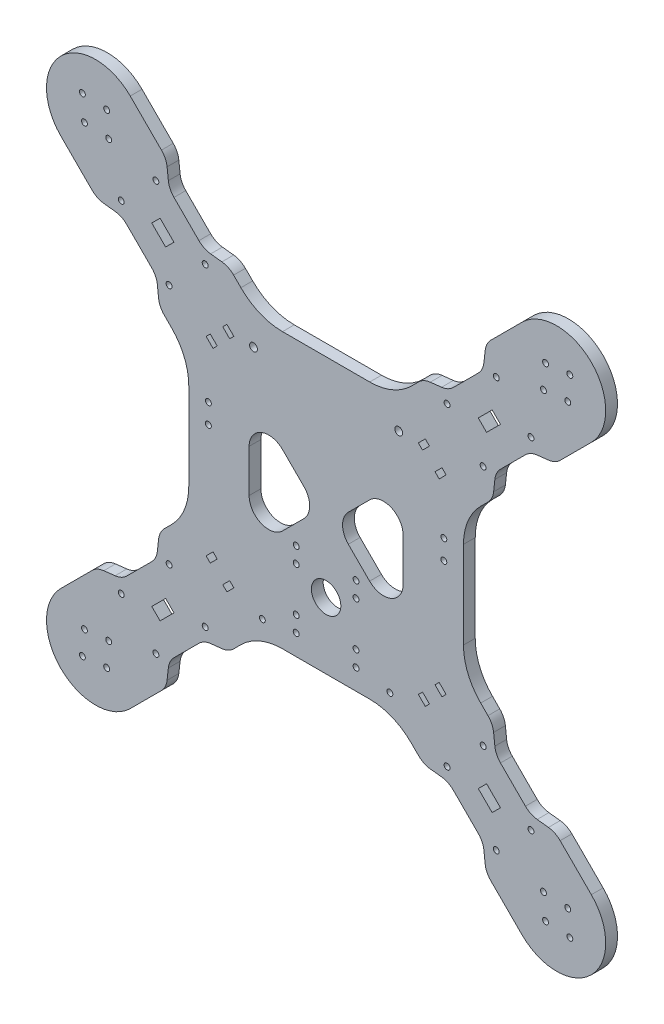
from build123d import *

# Parameters (mm, degrees)
BOSS_EXTRUDE1_DEPTH      = 6
FILLET1_R                = 30
SKETCH8_R                = 1.5
CUT_EXTRUDE1_DEPTH       = 202.614731605
SKETCH9_R                = 1.5
CUT_EXTRUDE2_DEPTH       = 202.614731605
MIRROR2_COPY_1_SKETCH_R  = 1.5
MIRROR2_COPY_1_DEPTH     = 202.614731605
MIRROR2_COPY_2_SKETCH_R  = 1.5
MIRROR2_COPY_2_DEPTH     = 202.614731605
MIRROR2_COPY_3_SKETCH_R  = 1.5
MIRROR2_COPY_3_DEPTH     = 202.614731605
MIRROR2_COPY_4_SKETCH_R  = 1.5
MIRROR2_COPY_4_DEPTH     = 202.614731605
CUT_EXTRUDE3_DEPTH       = 202.614731605
CUT_EXTRUDE3_DEPTH_BACK  = 202.614731605
SKETCH10_R               = 1.5
SKETCH10_R_2             = 1.499999999
SKETCH10_R_3             = 7.5
SKETCH10_R_4             = 2
FILLET2_R                = 10
CUT_EXTRUDE4_DEPTH       = 202.614731605
CIRPATTERN2_COUNT        = 4
CIRPATTERN2_COPY_1_DEPTH = 202.614731605
CIRPATTERN2_COPY_2_DEPTH = 202.614731605
CIRPATTERN2_COPY_3_DEPTH = 202.614731605
FILLET3_R                = 10


with BuildPart() as part:
    # Sketch4 → Boss-Extrude1 (new body)
    with BuildSketch(Plane.XY):
        with BuildLine():
            Line((-70, -34.644660941), (-70, 34.644660941))
            Line((-70, 34.644660941), (-135.17766953, 99.82233047))
            ThreePointArc((-135.17766953, 99.82233047), (-135.17766953, 135.17766953), (-99.82233047, 135.17766953))
            Line((-99.82233047, 135.17766953), (-34.644660941, 70))
            Line((-34.644660941, 70), (34.644660941, 70))
            Line((34.644660941, 70), (99.82233047, 135.17766953))
            ThreePointArc((99.82233047, 135.17766953), (135.17766953, 135.17766953), (135.17766953, 99.82233047))
            Line((135.17766953, 99.82233047), (70, 34.644660941))
            Line((70, 34.644660941), (70, -34.644660941))
            Line((70, -34.644660941), (135.17766953, -99.82233047))
            ThreePointArc((135.17766953, -99.82233047), (135.17766953, -135.17766953), (99.82233047, -135.17766953))
            Line((99.82233047, -135.17766953), (34.644660941, -70))
            Line((34.644660941, -70), (-34.644660941, -70))
            Line((-34.644660941, -70), (-99.82233047, -135.17766953))
            ThreePointArc((-99.82233047, -135.17766953), (-135.17766953, -135.17766953), (-135.17766953, -99.82233047))
            Line((-135.17766953, -99.82233047), (-70, -34.644660941))
        make_face()
    extrude(amount=BOSS_EXTRUDE1_DEPTH)

    # Fillet1
    fillet1_edges = [part.edges().sort_by_distance(p)[0] for p in [
        (34.644660941, -70, 3),
        (70, -34.644660941, 3),
        (70, 34.644660941, 3),
        (34.644660941, 70, 3),
        (-34.644660941, 70, 3),
        (-70, 34.644660941, 3),
        (-70, -34.644660941, 3),
        (-34.644660941, -70, 3),
    ]]
    fillet(fillet1_edges, radius=FILLET1_R)

    # Sketch8 → Cut-Extrude1 (cut, symmetric)
    with BuildSketch(Plane.XY.offset(6)):
        with Locations((-104.418524548, 86.740855018)):
            Circle(SKETCH8_R)
        with Locations((-80.023340597, 61.638564286)):
            Circle(SKETCH8_R)
        with Locations((-86.740855018, 104.418524548)):
            Circle(SKETCH8_R)
        with Locations((-61.638564286, 80.023340597)):
            Circle(SKETCH8_R)
        Polygon((-88.862175362, 84.619534675), (-84.619534675, 88.862175362), (-77.548466863, 81.79110755), (-81.79110755, 77.548466863), align=None)
    cut_extrude1 = extrude(amount=CUT_EXTRUDE1_DEPTH, both=True, mode=Mode.SUBTRACT)

    # Sketch9 → Cut-Extrude2 (cut, symmetric)
    with BuildSketch(Plane.XY.offset(6)):
        with Locations((-124.217514421, 124.217514421)):
            Circle(SKETCH9_R)
        with Locations((-110.782485579, 110.782485579)):
            Circle(SKETCH9_R)
        with Locations((-123.156854249, 111.843145751)):
            Circle(SKETCH9_R)
        with Locations((-111.843145751, 123.156854249)):
            Circle(SKETCH9_R)
    cut_extrude2 = extrude(amount=CUT_EXTRUDE2_DEPTH, both=True, mode=Mode.SUBTRACT)

    # Mirror1: Cut-Extrude1, Cut-Extrude2 across plane
    add(cut_extrude1.mirror(Plane(origin=(0, 0, 0), x_dir=(0, 0, 1), z_dir=(1, 0, 0))), mode=Mode.SUBTRACT)
    add(cut_extrude2.mirror(Plane(origin=(0, 0, 0), x_dir=(0, 0, 1), z_dir=(1, 0, 0))), mode=Mode.SUBTRACT)

    # Mirror2 copy 1 sketch → Mirror2 copy 1 (cut, symmetric)
    with BuildSketch(Plane(origin=(0, 0, 6), x_dir=(-1, 0, 0), z_dir=(0, 0, 1))):
        with Locations((-104.418524548, 86.740855018)):
            Circle(MIRROR2_COPY_1_SKETCH_R)
        with Locations((-80.023340597, 61.638564286)):
            Circle(MIRROR2_COPY_1_SKETCH_R)
        with Locations((-86.740855018, 104.418524548)):
            Circle(MIRROR2_COPY_1_SKETCH_R)
        with Locations((-61.638564286, 80.023340597)):
            Circle(MIRROR2_COPY_1_SKETCH_R)
        Polygon((-88.862175362, 84.619534675), (-84.619534675, 88.862175362), (-77.548466863, 81.79110755), (-81.79110755, 77.548466863), align=None)
    extrude(amount=MIRROR2_COPY_1_DEPTH, both=True, mode=Mode.SUBTRACT)

    # Mirror2 copy 2 sketch → Mirror2 copy 2 (cut, symmetric)
    with BuildSketch(Plane(origin=(0, 0, 6), x_dir=(-1, 0, 0), z_dir=(0, 0, 1))):
        with Locations((-124.217514421, 124.217514421)):
            Circle(MIRROR2_COPY_2_SKETCH_R)
        with Locations((-110.782485579, 110.782485579)):
            Circle(MIRROR2_COPY_2_SKETCH_R)
        with Locations((-123.156854249, 111.843145751)):
            Circle(MIRROR2_COPY_2_SKETCH_R)
        with Locations((-111.843145751, 123.156854249)):
            Circle(MIRROR2_COPY_2_SKETCH_R)
    extrude(amount=MIRROR2_COPY_2_DEPTH, both=True, mode=Mode.SUBTRACT)

    # Mirror2 copy 3 sketch → Mirror2 copy 3 (cut, symmetric)
    with BuildSketch(Plane.XY.offset(6)):
        with Locations((-104.418524548, -86.740855018)):
            Circle(MIRROR2_COPY_3_SKETCH_R)
        with Locations((-80.023340597, -61.638564286)):
            Circle(MIRROR2_COPY_3_SKETCH_R)
        with Locations((-86.740855018, -104.418524548)):
            Circle(MIRROR2_COPY_3_SKETCH_R)
        with Locations((-61.638564286, -80.023340597)):
            Circle(MIRROR2_COPY_3_SKETCH_R)
        Polygon((-88.862175362, -84.619534675), (-84.619534675, -88.862175362), (-77.548466863, -81.79110755), (-81.79110755, -77.548466863), align=None)
    extrude(amount=MIRROR2_COPY_3_DEPTH, both=True, mode=Mode.SUBTRACT)

    # Mirror2 copy 4 sketch → Mirror2 copy 4 (cut, symmetric)
    with BuildSketch(Plane.XY.offset(6)):
        with Locations((-124.217514421, -124.217514421)):
            Circle(MIRROR2_COPY_4_SKETCH_R)
        with Locations((-110.782485579, -110.782485579)):
            Circle(MIRROR2_COPY_4_SKETCH_R)
        with Locations((-123.156854249, -111.843145751)):
            Circle(MIRROR2_COPY_4_SKETCH_R)
        with Locations((-111.843145751, -123.156854249)):
            Circle(MIRROR2_COPY_4_SKETCH_R)
    extrude(amount=MIRROR2_COPY_4_DEPTH, both=True, mode=Mode.SUBTRACT)

    # Sketch10 → Cut-Extrude3 (cut, two sides: drawn at the far end of the back side and taken through both)
    with BuildSketch(Plane.XY.offset(6).offset(-CUT_EXTRUDE3_DEPTH_BACK)):
        with Locations((-60, 20)):
            Circle(SKETCH10_R)
        with Locations((-60, 10)):
            Circle(SKETCH10_R)
        with Locations((60, 20)):
            Circle(SKETCH10_R)
        with Locations((60, 10)):
            Circle(SKETCH10_R)
        with Locations((-15.249999999, -21)):
            Circle(SKETCH10_R_2)
        with Locations((15.249999999, -21)):
            Circle(SKETCH10_R)
        with Locations((-15.249999999, -51.5)):
            Circle(SKETCH10_R_2)
        with Locations((15.249999999, -51.5)):
            Circle(SKETCH10_R)
        with Locations((0, -36.249999999)):
            Circle(SKETCH10_R_3)
        with Locations((32.5, -62)):
            Circle(SKETCH10_R)
        with Locations((-32.5, -62)):
            Circle(SKETCH10_R)
        with Locations((15.250000001, -29)):
            Circle(SKETCH10_R)
        with Locations((-15.249999999, -29)):
            Circle(SKETCH10_R)
        with Locations((15.250000001, -59.5)):
            Circle(SKETCH10_R)
        with Locations((-15.249999999, -59.5)):
            Circle(SKETCH10_R_2)
        with Locations((-37, 55.742640687)):
            Circle(SKETCH10_R_4)
        with Locations((37, 55.742640687)):
            Circle(SKETCH10_R_4)
        Polygon((-49.142135624, -53.384776311), (-47.02081528, -55.506096654), (-50.556349186, -59.04163056), (-52.67766953, -56.920310217), align=None)
        Polygon((-4.242640687, 0), (-39.242640687, 35), (-39.242640687, -35), align=None)
        Polygon((39.242640687, 35), (39.242640687, -35), (4.242640687, 0), align=None)
        Polygon((-57.627416998, -44.899494937), (-55.506096654, -47.02081528), (-59.04163056, -50.556349186), (-61.162950904, -48.435028843), align=None)
        Polygon((-61.162950904, 48.435028843), (-59.04163056, 50.556349186), (-55.506096654, 47.02081528), (-57.627416998, 44.899494937), align=None)
        Polygon((57.627416998, 44.899494937), (55.506096654, 47.02081528), (59.04163056, 50.556349186), (61.162950904, 48.435028843), align=None)
        Polygon((61.162950904, -48.435028843), (57.627416998, -44.899494937), (55.506096654, -47.02081528), (59.04163056, -50.556349186), align=None)
        Polygon((-52.67766953, 56.920310217), (-50.556349186, 59.04163056), (-47.02081528, 55.506096654), (-49.142135624, 53.384776311), align=None)
        Polygon((52.67766953, -56.920310217), (49.142135624, -53.384776311), (47.02081528, -55.506096654), (50.556349186, -59.04163056), align=None)
        Polygon((49.142135624, 53.384776311), (47.02081528, 55.506096654), (50.556349186, 59.04163056), (52.67766953, 56.920310217), align=None)
    extrude(amount=CUT_EXTRUDE3_DEPTH + CUT_EXTRUDE3_DEPTH_BACK, mode=Mode.SUBTRACT)

    # Fillet2
    fillet2_edges = [part.edges().sort_by_distance(p)[0] for p in [
        (4.242640687, 0, 3),
        (39.242640687, -35, 3),
        (39.242640687, 35, 3),
        (-39.242640687, -35, 3),
        (-39.242640687, 35, 3),
        (-4.242640687, 0, 3),
    ]]
    fillet(fillet2_edges, radius=FILLET2_R)

    # Sketch11 → Cut-Extrude4 (cut, symmetric)
    with BuildSketch(Plane.XY.offset(6)):
        Polygon((-80.023340597, 104.064971157), (-62.345671067, 86.387301628), (-49.617749006, 84.973088065), (-81.437554159, 116.792893219), align=None)
    cut_extrude4 = extrude(amount=CUT_EXTRUDE4_DEPTH, both=True, mode=Mode.SUBTRACT)

    # Mirror4: Cut-Extrude4 across plane
    add(cut_extrude4.mirror(Plane(origin=(0, 0, 0), x_dir=(0, 0, 1), z_dir=(0.7071067811865474, 0.7071067811865477, 0))), mode=Mode.SUBTRACT)

    # CirPattern2: Cut-Extrude4 ×4 about axis
    cirpattern2_axis = Axis((0, 0, 0), (0, 0, 1))
    for i in range(1, CIRPATTERN2_COUNT):
        add(cut_extrude4.rotate(cirpattern2_axis, i * 360 / CIRPATTERN2_COUNT), mode=Mode.SUBTRACT)

    # CirPattern2 copy 1 sketch → CirPattern2 copy 1 (cut, symmetric)
    with BuildSketch(Plane.XY.offset(6)):
        Polygon((-80.023340597, -104.064971157), (-62.345671067, -86.387301628), (-49.617749006, -84.973088065), (-81.437554159, -116.792893219), align=None)
    extrude(amount=CIRPATTERN2_COPY_1_DEPTH, both=True, mode=Mode.SUBTRACT)

    # CirPattern2 copy 2 sketch → CirPattern2 copy 2 (cut, symmetric)
    with BuildSketch(Plane(origin=(0, 0, 6), x_dir=(0, 1, 0), z_dir=(0, 0, 1))):
        Polygon((-80.023340597, -104.064971157), (-62.345671067, -86.387301628), (-49.617749006, -84.973088065), (-81.437554159, -116.792893219), align=None)
    extrude(amount=CIRPATTERN2_COPY_2_DEPTH, both=True, mode=Mode.SUBTRACT)

    # CirPattern2 copy 3 sketch → CirPattern2 copy 3 (cut, symmetric)
    with BuildSketch(Plane(origin=(0, 0, 6), x_dir=(-1, 0, 0), z_dir=(0, 0, 1))):
        Polygon((-80.023340597, -104.064971157), (-62.345671067, -86.387301628), (-49.617749006, -84.973088065), (-81.437554159, -116.792893219), align=None)
    extrude(amount=CIRPATTERN2_COPY_3_DEPTH, both=True, mode=Mode.SUBTRACT)

    # Fillet3
    fillet3_edges = [part.edges().sort_by_distance(p)[0] for p in [
        (-49.617749006, 84.973088065, 3),
        (-62.345671067, 86.387301628, 3),
        (-80.023340597, 104.064971157, 3),
        (-81.437554159, 116.792893219, 3),
        (116.792893219, 81.437554159, 3),
        (104.064971157, 80.023340597, 3),
        (86.387301628, 62.345671067, 3),
        (84.973088065, 49.617749006, 3),
        (80.023340597, 104.064971157, 3),
        (81.437554159, 116.792893219, 3),
        (62.345671067, 86.387301628, 3),
        (49.617749006, 84.973088065, 3),
        (116.792893219, -81.437554159, 3),
        (104.064971157, -80.023340597, 3),
        (86.387301628, -62.345671067, 3),
        (84.973088065, -49.617749006, 3),
        (81.437554159, -116.792893219, 3),
        (80.023340597, -104.064971157, 3),
        (62.345671067, -86.387301628, 3),
        (49.617749006, -84.973088065, 3),
        (-49.617749006, -84.973088065, 3),
        (-62.345671067, -86.387301628, 3),
        (-80.023340597, -104.064971157, 3),
        (-81.437554159, -116.792893219, 3),
        (-116.792893219, -81.437554159, 3),
        (-104.064971157, -80.023340597, 3),
        (-86.387301628, -62.345671067, 3),
        (-84.973088065, -49.617749006, 3),
        (-84.973088065, 49.617749006, 3),
        (-86.387301628, 62.345671067, 3),
        (-104.064971157, 80.023340597, 3),
        (-116.792893219, 81.437554159, 3),
    ]]
    fillet(fillet3_edges, radius=FILLET3_R)


solid = part.part
